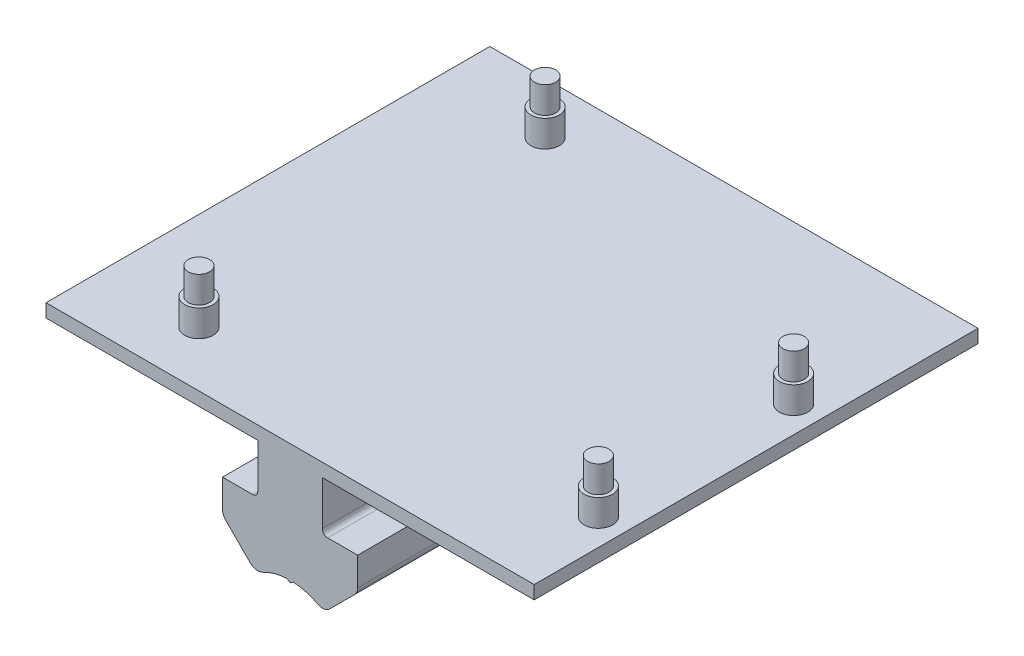
from build123d import *

# Parameters (mm, degrees)
BOSS_EXTRUDE1_DEPTH = 63.5
SKETCH3_R           = 1.524
BOSS_EXTRUDE2_DEPTH = 7.62
SKETCH4_R           = 2.032
BOSS_EXTRUDE3_DEPTH = 3.81


with BuildPart() as part:
    # Sketch1 → Boss-Extrude1 (new body)
    with BuildSketch(Plane.XY.offset(433.726101294)):
        with BuildLine():
            Line((12.262790096, 63.439286549), (12.817159361, 63.439286549))
            Line((12.817159361, 63.439286549), (13.759849728, 63.439286549))
            ThreePointArc((13.759849728, 63.439286549), (14.295836668, 63.661299609), (14.517849728, 64.197286549))
            Line((14.517849728, 64.197286549), (14.517849728, 67.981786549))
            Line((14.517849728, 67.981786549), (14.517849728, 70.521786549))
            Line((14.517849728, 70.521786549), (-15.788150272, 70.521786549))
            Line((-15.788150272, 70.521786549), (-15.788150272, 72.426786549))
            Line((-15.788150272, 72.426786549), (54.061849728, 72.426786549))
            Line((54.061849728, 72.426786549), (54.061849728, 70.521786549))
            Line((54.061849728, 70.521786549), (23.755849728, 70.521786549))
            Line((23.755849728, 70.521786549), (23.755849728, 67.981786549))
            Line((23.755849728, 67.981786549), (23.755849728, 64.197286549))
            ThreePointArc((23.755849728, 64.197286549), (23.977862788, 63.661299609), (24.513849728, 63.439286549))
            Line((24.513849728, 63.439286549), (28.805849728, 63.439286549))
            Line((28.805849728, 63.439286549), (28.805849728, 59.401079114))
            ThreePointArc((28.805849728, 59.401079114), (28.691364545, 58.825523232), (28.365338327, 58.337590516))
            Line((28.365338327, 58.337590516), (24.822387807, 54.794639996))
            ThreePointArc((24.822387807, 54.794639996), (23.982795062, 54.370887307), (23.055655666, 54.528668358))
            ThreePointArc((23.055655666, 54.528668358), (21.370192512, 55.198240561), (19.580150838, 55.489554446))
            Line((19.580150838, 55.489554446), (19.136849728, 55.179151668))
            Line((19.136849728, 55.179151668), (18.693548619, 55.489554446))
            ThreePointArc((18.693548619, 55.489554446), (16.903506945, 55.198240561), (15.218043791, 54.528668358))
            ThreePointArc((15.218043791, 54.528668358), (14.290904395, 54.370887307), (13.451311649, 54.794639996))
            Line((13.451311649, 54.794639996), (9.908361129, 58.337590516))
            ThreePointArc((9.908361129, 58.337590516), (9.582334911, 58.825523232), (9.467849728, 59.401079114))
            Line((9.467849728, 59.401079114), (9.467849728, 63.439286549))
            Line((9.467849728, 63.439286549), (12.262790096, 63.439286549))
        make_face()
    extrude(amount=-BOSS_EXTRUDE1_DEPTH)

    # Sketch3 → Boss-Extrude2 (add)
    with BuildSketch(Plane(origin=(0, 72.426786549, 0), x_dir=(1, 0, 0), z_dir=(0, 1, 0))):
        with Locations((-0.548150272, -377.554863046)):
            Circle(SKETCH3_R)
        with Locations((50.251849728, -392.794863046)):
            Circle(SKETCH3_R)
        with Locations((50.251849728, -420.734863046)):
            Circle(SKETCH3_R)
        with Locations((-1.818150272, -425.814863046)):
            Circle(SKETCH3_R)
    extrude(amount=BOSS_EXTRUDE2_DEPTH)

    # Sketch4 → Boss-Extrude3 (add)
    with BuildSketch(Plane(origin=(0, 72.426786549, 0), x_dir=(1, 0, 0), z_dir=(0, 1, 0))):
        with Locations((-0.548150272, -377.554863046)):
            Circle(SKETCH4_R)
        with Locations((50.251849728, -392.794863046)):
            Circle(SKETCH4_R)
        with Locations((50.251849728, -420.734863046)):
            Circle(SKETCH4_R)
        with Locations((-1.818150272, -425.814863046)):
            Circle(SKETCH4_R)
    extrude(amount=BOSS_EXTRUDE3_DEPTH)


solid = part.part
